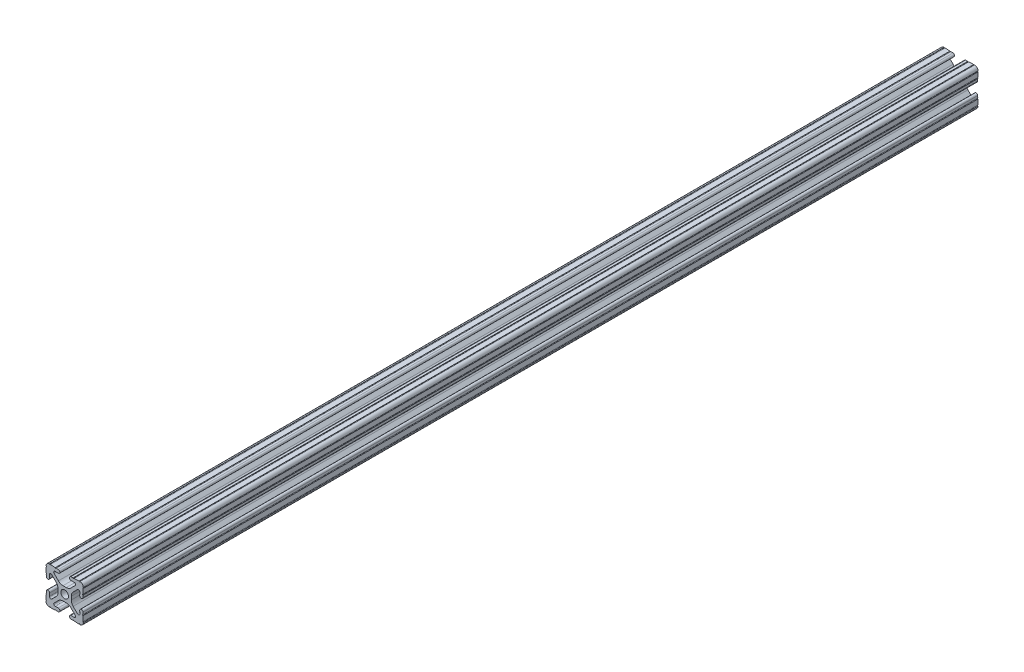
from build123d import *

# Parameters (mm, degrees)
SKETCH3_R      = 2.6035
EXTRUDE1_DEPTH = 304.8


with BuildPart() as part:
    # Sketch3 → Extrude1 (new body, symmetric)
    with BuildSketch(Plane.XY):
        with BuildLine():
            Line((-1.115277175, 4.5085), (1.115277175, 4.5085))
            ThreePointArc((1.115277175, 4.5085), (2.806584872, 4.844922018), (4.240406305, 5.80297087))
            Line((4.240406305, 5.80297087), (7.148423664, 8.710988229))
            ThreePointArc((7.148423664, 8.710988229), (7.349906316, 9.772227925), (6.436353897, 10.348636575))
            Line((6.436353897, 10.348636575), (4.381960454, 10.276895575))
            ThreePointArc((4.381960454, 10.276895575), (3.239173075, 11.342562046), (4.304839546, 12.485349424))
            Line((4.304839546, 12.485349424), (5.728246175, 12.535055879))
            ThreePointArc((5.728246175, 12.535055879), (6.054756855, 12.230579745), (6.35923299, 12.557090424))
            Line((6.35923299, 12.557090424), (9.782092278, 12.676619304))
            ThreePointArc((9.782092278, 12.676619304), (10.108602958, 12.37214317), (10.413079092, 12.69865385))
            ThreePointArc((10.413079092, 12.69865385), (12.052764565, 12.052764565), (12.69865385, 10.413079092))
            ThreePointArc((12.69865385, 10.413079092), (12.37214317, 10.108602958), (12.676619304, 9.782092278))
            Line((12.676619304, 9.782092278), (12.557090424, 6.35923299))
            ThreePointArc((12.557090424, 6.35923299), (12.230579745, 6.054756855), (12.535055879, 5.728246175))
            Line((12.535055879, 5.728246175), (12.485349424, 4.304839546))
            ThreePointArc((12.485349424, 4.304839546), (11.342562046, 3.239173075), (10.276895575, 4.381960454))
            Line((10.276895575, 4.381960454), (10.348636575, 6.436353897))
            ThreePointArc((10.348636575, 6.436353897), (9.772227925, 7.349906316), (8.710988229, 7.148423664))
            Line((8.710988229, 7.148423664), (5.80297087, 4.240406305))
            ThreePointArc((5.80297087, 4.240406305), (4.844922018, 2.806584872), (4.5085, 1.115277175))
            Line((4.5085, 1.115277175), (4.5085, -1.115277175))
            ThreePointArc((4.5085, -1.115277175), (4.844922018, -2.806584872), (5.80297087, -4.240406305))
            Line((5.80297087, -4.240406305), (8.710988229, -7.148423664))
            ThreePointArc((8.710988229, -7.148423664), (9.772227925, -7.349906316), (10.348636575, -6.436353897))
            Line((10.348636575, -6.436353897), (10.276895575, -4.381960454))
            ThreePointArc((10.276895575, -4.381960454), (11.342562046, -3.239173075), (12.485349424, -4.304839546))
            Line((12.485349424, -4.304839546), (12.535055879, -5.728246175))
            ThreePointArc((12.535055879, -5.728246175), (12.230579745, -6.054756855), (12.557090424, -6.35923299))
            Line((12.557090424, -6.35923299), (12.676619304, -9.782092278))
            ThreePointArc((12.676619304, -9.782092278), (12.37214317, -10.108602958), (12.69865385, -10.413079092))
            ThreePointArc((12.69865385, -10.413079092), (12.052764565, -12.052764565), (10.413079092, -12.69865385))
            ThreePointArc((10.413079092, -12.69865385), (10.108602958, -12.37214317), (9.782092278, -12.676619304))
            Line((9.782092278, -12.676619304), (6.35923299, -12.557090424))
            ThreePointArc((6.35923299, -12.557090424), (6.054756855, -12.230579745), (5.728246175, -12.535055879))
            Line((5.728246175, -12.535055879), (4.304839546, -12.485349424))
            ThreePointArc((4.304839546, -12.485349424), (3.239173075, -11.342562046), (4.381960454, -10.276895575))
            Line((4.381960454, -10.276895575), (6.436353897, -10.348636575))
            ThreePointArc((6.436353897, -10.348636575), (7.349906316, -9.772227925), (7.148423664, -8.710988229))
            Line((7.148423664, -8.710988229), (4.240406305, -5.80297087))
            ThreePointArc((4.240406305, -5.80297087), (2.806584872, -4.844922018), (1.115277175, -4.5085))
            Line((1.115277175, -4.5085), (-1.115277175, -4.5085))
            ThreePointArc((-1.115277175, -4.5085), (-2.806584872, -4.844922018), (-4.240406305, -5.80297087))
            Line((-4.240406305, -5.80297087), (-7.148423664, -8.710988229))
            ThreePointArc((-7.148423664, -8.710988229), (-7.349906316, -9.772227925), (-6.436353897, -10.348636575))
            Line((-6.436353897, -10.348636575), (-4.381960454, -10.276895575))
            ThreePointArc((-4.381960454, -10.276895575), (-3.239173075, -11.342562046), (-4.304839546, -12.485349424))
            Line((-4.304839546, -12.485349424), (-5.728246175, -12.535055879))
            ThreePointArc((-5.728246175, -12.535055879), (-6.054756855, -12.230579745), (-6.35923299, -12.557090424))
            Line((-6.35923299, -12.557090424), (-9.782092278, -12.676619304))
            ThreePointArc((-9.782092278, -12.676619304), (-10.108602958, -12.37214317), (-10.413079092, -12.69865385))
            ThreePointArc((-10.413079092, -12.69865385), (-12.052764565, -12.052764565), (-12.69865385, -10.413079092))
            ThreePointArc((-12.69865385, -10.413079092), (-12.37214317, -10.108602958), (-12.676619304, -9.782092278))
            Line((-12.676619304, -9.782092278), (-12.557090424, -6.35923299))
            ThreePointArc((-12.557090424, -6.35923299), (-12.230579745, -6.054756855), (-12.535055879, -5.728246175))
            Line((-12.535055879, -5.728246175), (-12.485349424, -4.304839546))
            ThreePointArc((-12.485349424, -4.304839546), (-11.342562046, -3.239173075), (-10.276895575, -4.381960454))
            Line((-10.276895575, -4.381960454), (-10.348636575, -6.436353897))
            ThreePointArc((-10.348636575, -6.436353897), (-9.772227925, -7.349906316), (-8.710988229, -7.148423664))
            Line((-8.710988229, -7.148423664), (-5.80297087, -4.240406305))
            ThreePointArc((-5.80297087, -4.240406305), (-4.844922018, -2.806584872), (-4.5085, -1.115277175))
            Line((-4.5085, -1.115277175), (-4.5085, 1.115277175))
            ThreePointArc((-4.5085, 1.115277175), (-4.844922018, 2.806584872), (-5.80297087, 4.240406305))
            Line((-5.80297087, 4.240406305), (-8.710988229, 7.148423664))
            ThreePointArc((-8.710988229, 7.148423664), (-9.772227925, 7.349906316), (-10.348636575, 6.436353897))
            Line((-10.348636575, 6.436353897), (-10.276895575, 4.381960454))
            ThreePointArc((-10.276895575, 4.381960454), (-11.342562046, 3.239173075), (-12.485349424, 4.304839546))
            Line((-12.485349424, 4.304839546), (-12.535055879, 5.728246175))
            ThreePointArc((-12.535055879, 5.728246175), (-12.230579745, 6.054756855), (-12.557090424, 6.35923299))
            Line((-12.557090424, 6.35923299), (-12.676619304, 9.782092278))
            ThreePointArc((-12.676619304, 9.782092278), (-12.37214317, 10.108602958), (-12.69865385, 10.413079092))
            ThreePointArc((-12.69865385, 10.413079092), (-12.052764565, 12.052764565), (-10.413079092, 12.69865385))
            ThreePointArc((-10.413079092, 12.69865385), (-10.108602958, 12.37214317), (-9.782092278, 12.676619304))
            Line((-9.782092278, 12.676619304), (-6.35923299, 12.557090424))
            ThreePointArc((-6.35923299, 12.557090424), (-6.054756855, 12.230579745), (-5.728246175, 12.535055879))
            Line((-5.728246175, 12.535055879), (-4.304839546, 12.485349424))
            ThreePointArc((-4.304839546, 12.485349424), (-3.239173075, 11.342562046), (-4.381960454, 10.276895575))
            Line((-4.381960454, 10.276895575), (-6.436353897, 10.348636575))
            ThreePointArc((-6.436353897, 10.348636575), (-7.349906316, 9.772227925), (-7.148423664, 8.710988229))
            Line((-7.148423664, 8.710988229), (-4.240406305, 5.80297087))
            ThreePointArc((-4.240406305, 5.80297087), (-2.806584872, 4.844922018), (-1.115277175, 4.5085))
        make_face()
        Circle(SKETCH3_R, mode=Mode.SUBTRACT)
    extrude(amount=EXTRUDE1_DEPTH, both=True)


solid = part.part
